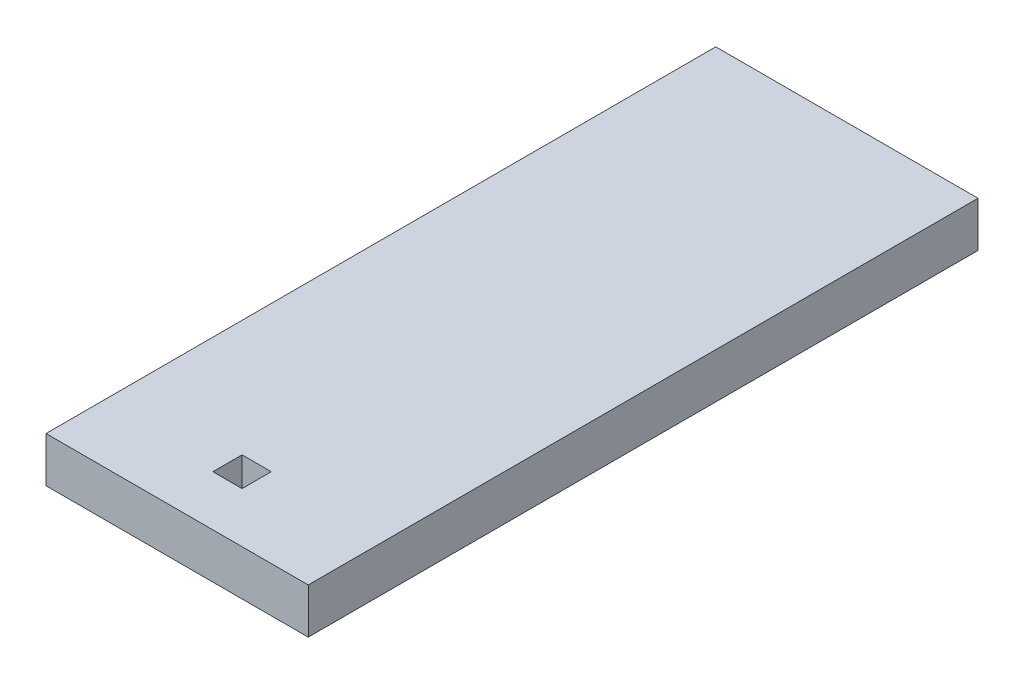
from build123d import *

# Parameters (mm, degrees)
SKETCH1_W           = 18.4
SKETCH1_H           = 46.99
SKETCH1_W_2         = 2.05
SKETCH1_H_2         = 2.05
SKETCH1_W_3         = 3.175
BOSS_EXTRUDE1_DEPTH = 3.175
SKETCH2_W           = 3.175
SKETCH2_H           = 46.99
CUT_EXTRUDE1_DEPTH  = 4.175


with BuildPart() as part:
    # Sketch1 → Boss-Extrude1 (new body)
    with BuildSketch(Plane(origin=(0, 0, 0), x_dir=(1, 0, 0), z_dir=(0, 1, 0))):
        Rectangle(SKETCH1_W, SKETCH1_H)
        with Locations((0, -18.93924342)):
            Rectangle(SKETCH1_W_2, SKETCH1_H_2, mode=Mode.SUBTRACT)
        with Locations((-10.7875, 0)):
            Rectangle(SKETCH1_W_3, SKETCH1_H)
    extrude(amount=BOSS_EXTRUDE1_DEPTH)

    # Sketch2 → Cut-Extrude1 (cut, through all)
    with BuildSketch(Plane(origin=(0, 3.175, 0), x_dir=(1, 0, 0), z_dir=(0, 1, 0))):
        with Locations((-10.7875, 0)):
            Rectangle(SKETCH2_W, SKETCH2_H)
    extrude(amount=-CUT_EXTRUDE1_DEPTH, mode=Mode.SUBTRACT)


solid = part.part
